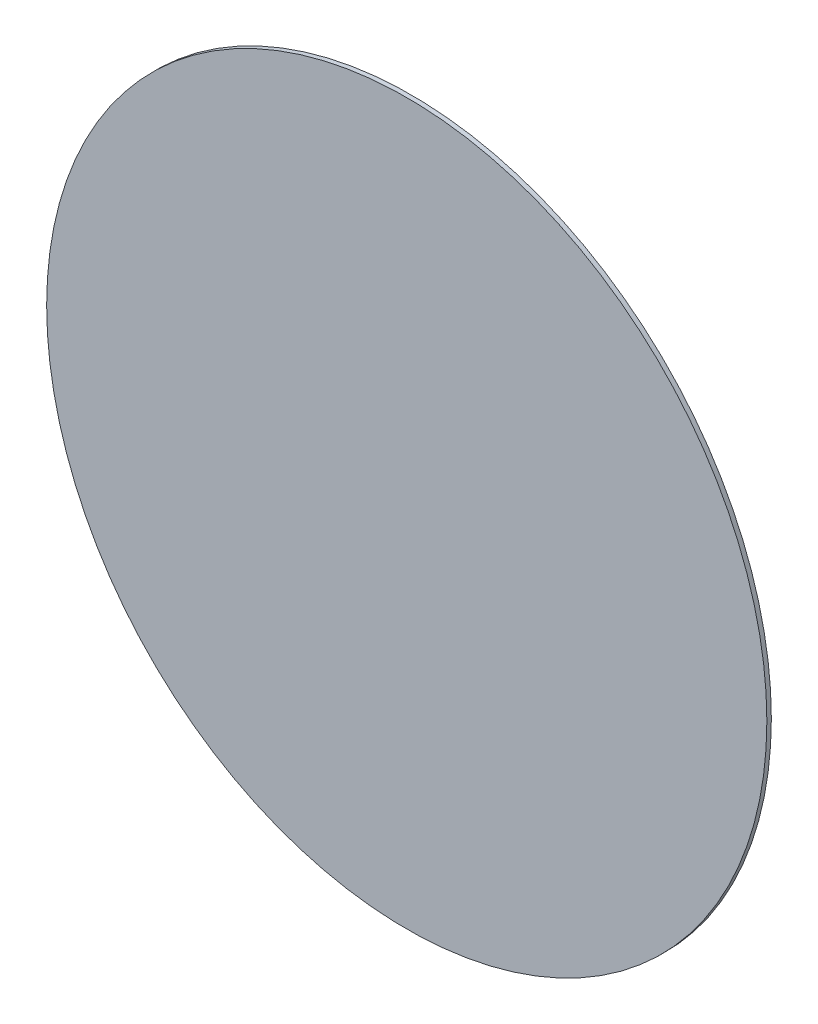
from build123d import *

# Parameters (mm, degrees)
ESBO_O1_R                = 801.383310629
RESSALTO_EXTRUS_O1_DEPTH = 10


with BuildPart() as part:
    # Esboço1 → Ressalto-extrusão1 (new body)
    with BuildSketch(Plane.XY.offset(38931.700196057)):
        with Locations((-33142.787367345, -18960.949835815)):
            Circle(ESBO_O1_R)
    extrude(amount=RESSALTO_EXTRUS_O1_DEPTH)


solid = part.part
